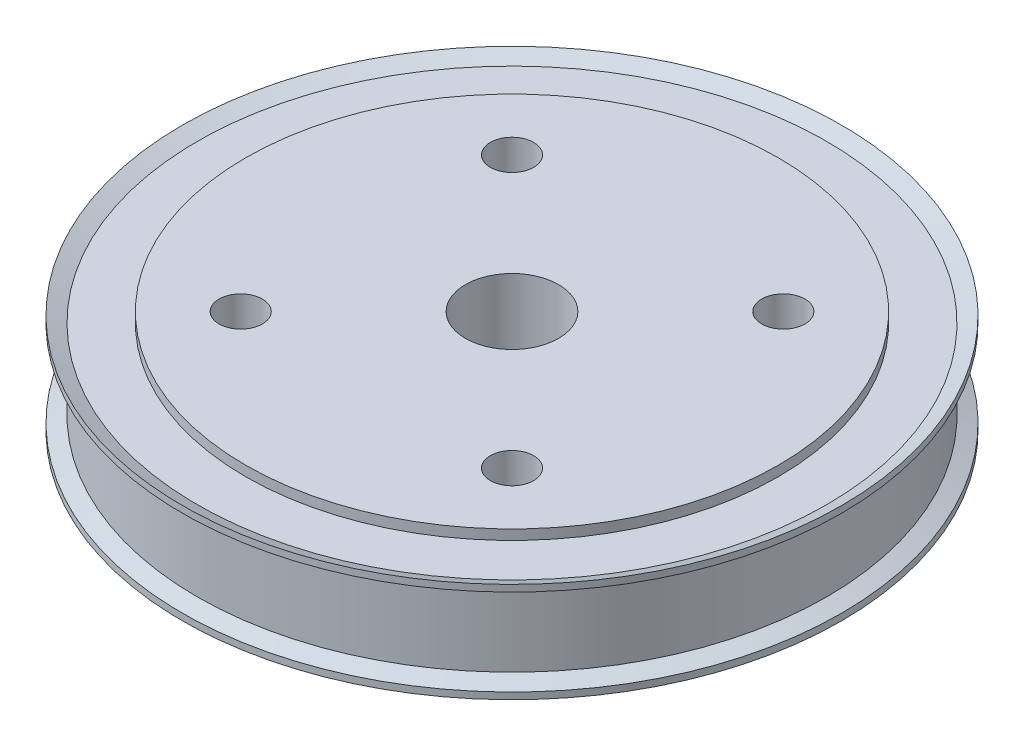
from build123d import *

# Parameters (mm, degrees)
HOLE_WIZARD_6_5_6_5_1_D = 6.5


with BuildPart() as part:
    # 草圖1 → 旋轉1 (revolve)
    with BuildSketch(Plane.XY):
        Polygon((7, -8), (7, 8), (40, 8), (40, 5.5), (47.265, 5.5), (47.265, -5.5), (40, -5.5), (40, -8), align=None)
    revolve(axis=Axis((0, 49.340027701, 0), (0, -1, 0)))

    # 草圖7 → 旋轉2 (revolve)
    with BuildSketch(Plane.XY):
        Polygon((-49.5, -6.5), (-47.265, -5.5), (-40, -5.5), (-40, -6.5), (-47.265, -6.5), (-49.5, -7.5), align=None)
    revolve_2 = revolve(axis=Axis((0, 0, 0), (0, 1, 0)))

    # 鏡射1: 旋轉2 across plane
    add(revolve_2.mirror(Plane.ZX))

    # Ø6.5 (6.5) 直徑孔1 (through all)
    with Locations(Plane(origin=(0, 8, 0), x_dir=(1, 0, 0), z_dir=(0, 1, 0))):
        with Locations((-20.375, 20.375), (20.375, 20.375), (20.375, -20.375), (-20.375, -20.375), (0, 0)):
            Hole(HOLE_WIZARD_6_5_6_5_1_D / 2)


solid = part.part
